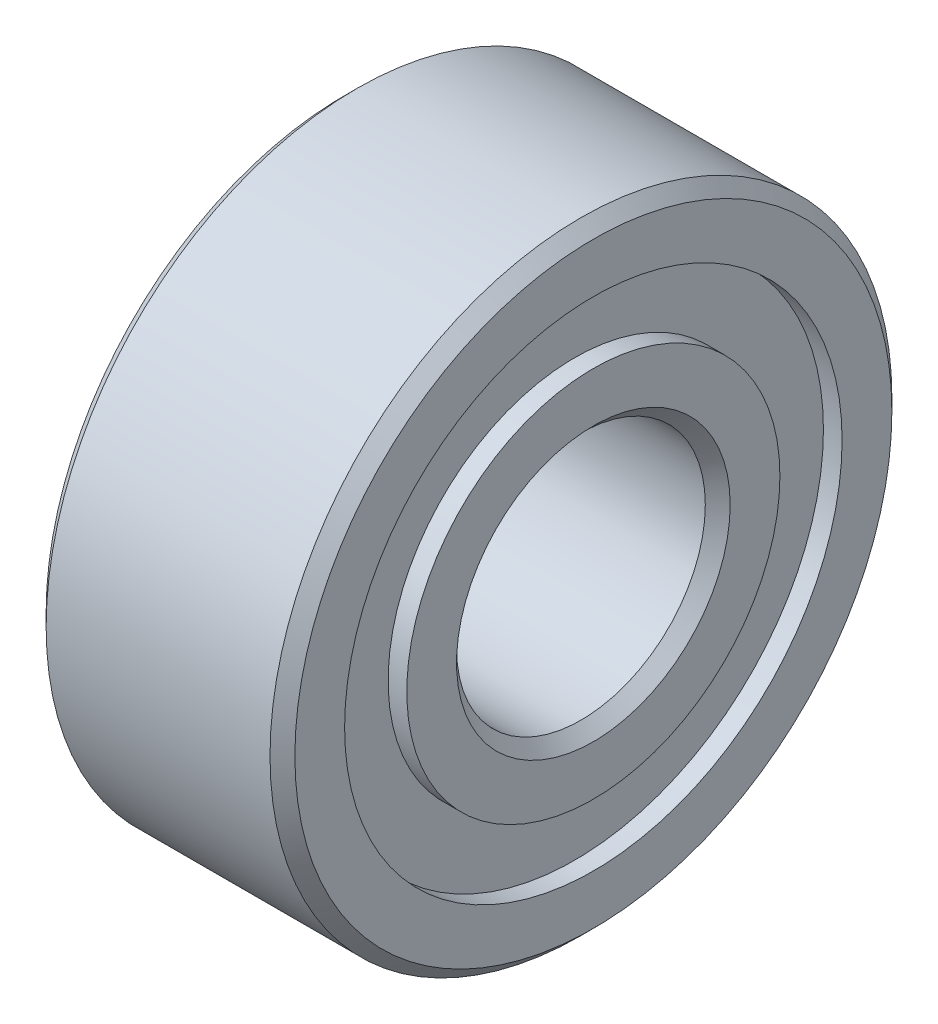
from build123d import *

# Parameters (mm, degrees)
SKETCH_1_R          = 5
SKETCH_1_R_2        = 2
EXTRUDE_1_DEPTH     = 4
SKETCH_2_R          = 4
SKETCH_2_R_2        = 3
CUT_EXTRUDE_1_DEPTH = 0.3
CHAMFER_1_SIZE      = 0.2
SKETCH_3_R          = 4
SKETCH_3_R_2        = 3
CUT_EXTRUDE_2_DEPTH = 0.3


with BuildPart() as part:
    # 草图1 → 凸台-拉伸1 (new body)
    with BuildSketch(Plane(origin=(0, 0, 0), x_dir=(0, 0, -1), z_dir=(1, 0, 0))):
        Circle(SKETCH_1_R)
        Circle(SKETCH_1_R_2, mode=Mode.SUBTRACT)
    extrude(amount=EXTRUDE_1_DEPTH)

    # 草图2 → 切除-拉伸1 (cut)
    with BuildSketch(Plane(origin=(4, 0, 0), x_dir=(0, 0, -1), z_dir=(1, 0, 0))):
        with Locations((-0.000375625, 0)):
            Circle(SKETCH_2_R)
        with Locations((-0.000375625, 0)):
            Circle(SKETCH_2_R_2, mode=Mode.SUBTRACT)
    extrude(amount=-CUT_EXTRUDE_1_DEPTH, mode=Mode.SUBTRACT)

    # 倒角1
    chamfer_1_edges = [part.edges().sort_by_distance(p)[0] for p in [
        (0, 0, 5),
        (4, 0, 5),
        (0, 0, 2),
        (4, 0, 2),
    ]]
    chamfer(chamfer_1_edges, length=CHAMFER_1_SIZE)

    # 草图3 → 切除-拉伸2 (cut)
    with BuildSketch(Plane.ZY):
        Circle(SKETCH_3_R)
        Circle(SKETCH_3_R_2, mode=Mode.SUBTRACT)
    extrude(amount=-CUT_EXTRUDE_2_DEPTH, mode=Mode.SUBTRACT)


solid = part.part
